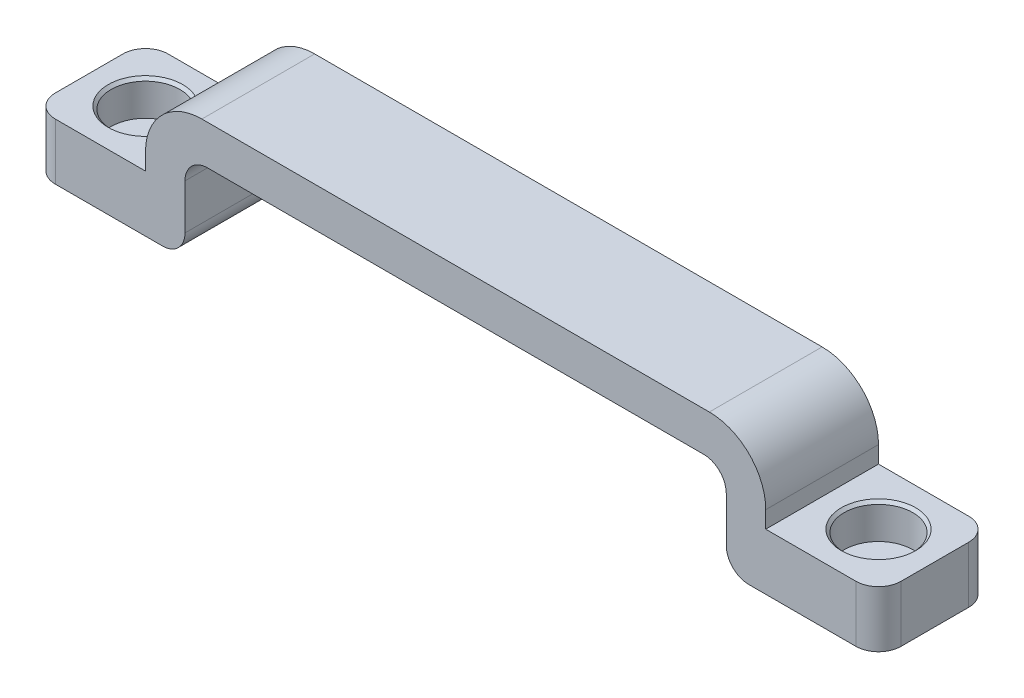
from build123d import *

# Parameters (mm, degrees)
BOSS_EXTRUDE1_DEPTH = 5
FILLET1_R           = 2
FILLET2_R           = 5
FILLET3_R           = 2
FILLET4_R           = 2
SKETCH3_R           = 3.05
CUT_EXTRUDE1_DEPTH  = 3.1
CHAMFER1_SIZE       = 0.25


with BuildPart() as part:
    # Sketch1 → Boss-Extrude1 (new body, symmetric)
    with BuildSketch(Plane.XY):
        Polygon((-27.5, 3.5), (27.5, 3.5), (27.5, -3), (37.5, -3), (37.5, -8), (27.5, -8), (24, -8), (24, 0), (-24, 0), (-24, -8), (-27.5, -8), (-37.5, -8), (-37.5, -3), (-27.5, -3), align=None)
    extrude(amount=BOSS_EXTRUDE1_DEPTH, both=True)

    # Fillet1
    fillet1_edges = [part.edges().sort_by_distance(p)[0] for p in [
        (24, 0, 0),
        (-24, 0, 0),
    ]]
    fillet(fillet1_edges, radius=FILLET1_R)

    # Fillet2
    fillet2_edges = [part.edges().sort_by_distance(p)[0] for p in [
        (-27.5, 3.5, 0),
        (27.5, 3.5, 0),
    ]]
    fillet(fillet2_edges, radius=FILLET2_R)

    # Fillet3
    fillet3_edges = [part.edges().sort_by_distance(p)[0] for p in [
        (37.5, -5.5, -5),
        (-37.5, -5.5, -5),
        (-37.5, -5.5, 5),
        (37.5, -5.5, 5),
    ]]
    fillet(fillet3_edges, radius=FILLET3_R)

    # Fillet4
    fillet4_edges = [part.edges().sort_by_distance(p)[0] for p in [
        (24, -8, 0),
        (-24, -8, 0),
    ]]
    fillet(fillet4_edges, radius=FILLET4_R)

    # Sketch3 → Cut-Extrude1 (cut)
    with BuildSketch(Plane(origin=(0, -3, 0), x_dir=(1, 0, 0), z_dir=(0, 1, 0))):
        with Locations((32.5, 0)):
            Circle(SKETCH3_R)
        with Locations((-32.5, 0)):
            Circle(SKETCH3_R)
    extrude(amount=-CUT_EXTRUDE1_DEPTH, mode=Mode.SUBTRACT)

    # Chamfer1
    chamfer1_edges = [part.edges().sort_by_distance(p)[0] for p in [
        (29.45, -3, 0),
        (-35.55, -3, 0),
    ]]
    chamfer(chamfer1_edges, length=CHAMFER1_SIZE)


solid = part.part
